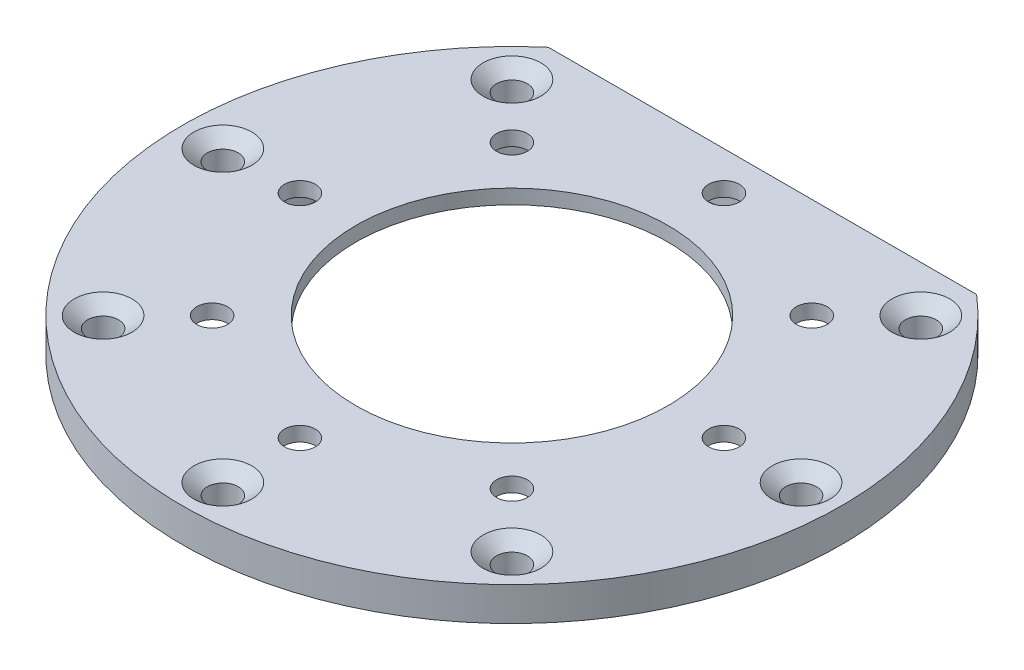
from build123d import *

# Parameters (mm, degrees)
ESQUISSE3_R                                    = 1.6
ENL_V_MAT_EXTRU_1_DEPTH                        = 4.5
FRAISAGE_POUR_VIS_T_TE_FRAIS_E_100_D           = 3.2
FRAISAGE_POUR_VIS_T_TE_FRAIS_E_100_CSINK_D     = 6
FRAISAGE_POUR_VIS_T_TE_FRAIS_E_100_CSINK_ANGLE = 100
R_P_TITION_CIRCULAIRE1_COUNT                   = 8
SKETCH1_W                                      = 44.436021424
SKETCH1_H                                      = 8.2
CUT_EXTRUDE1_DEPTH                             = 4.5


with BuildPart() as part:
    # Esquisse2 → Révolution1 (revolve)
    with BuildSketch(Plane.XY):
        Polygon((34.2, 0), (34.2, 3.5), (16.2, 3.5), (16.2, 2), (24.2, 2), (24.2, 0), align=None)
    revolve(axis=Axis((0, 37.373365456, 0), (0, -1, 0)))

    # Esquisse3 → Enlèv. mat.-Extru.1 (cut, through all)
    with BuildSketch(Plane(origin=(0, 3.5, 0), x_dir=(1, 0, 0), z_dir=(0, 1, 0))):
        with Locations((22, 0)):
            Circle(ESQUISSE3_R)
    enl_v_mat_extru_1 = extrude(amount=-ENL_V_MAT_EXTRU_1_DEPTH, mode=Mode.SUBTRACT)

    # Fraisage pour vis à tête fraisée (100) #01 (through all)
    with Locations(Plane(origin=(0, 3.5, 0), x_dir=(1, 0, 0), z_dir=(0, 1, 0))):
        with Locations((30, 0)):
            fraisage_pour_vis_t_te_frais_e_100 = CounterSinkHole(FRAISAGE_POUR_VIS_T_TE_FRAIS_E_100_D / 2, FRAISAGE_POUR_VIS_T_TE_FRAIS_E_100_CSINK_D / 2, counter_sink_angle=FRAISAGE_POUR_VIS_T_TE_FRAIS_E_100_CSINK_ANGLE)

    # Répétition circulaire1: Enlèv. mat.-Extru.1, Fraisage pour vis à tête fraisée (100) #01 ×8 about axis
    r_p_tition_circulaire1_axis = Axis((0, 0, 0), (0, 1, 0))
    for i in range(1, R_P_TITION_CIRCULAIRE1_COUNT):
        add(enl_v_mat_extru_1.rotate(r_p_tition_circulaire1_axis, i * 360 / R_P_TITION_CIRCULAIRE1_COUNT), mode=Mode.SUBTRACT)
        add(fraisage_pour_vis_t_te_frais_e_100.rotate(r_p_tition_circulaire1_axis, i * 360 / R_P_TITION_CIRCULAIRE1_COUNT), mode=Mode.SUBTRACT)

    # Sketch1 → Cut-Extrude1 (cut, through all)
    with BuildSketch(Plane(origin=(0, 0, 0), x_dir=(-1, 0, 0), z_dir=(0, -1, 0))):
        with Locations((0, 30.1)):
            Rectangle(SKETCH1_W, SKETCH1_H)
    extrude(amount=-CUT_EXTRUDE1_DEPTH, mode=Mode.SUBTRACT)


solid = part.part
